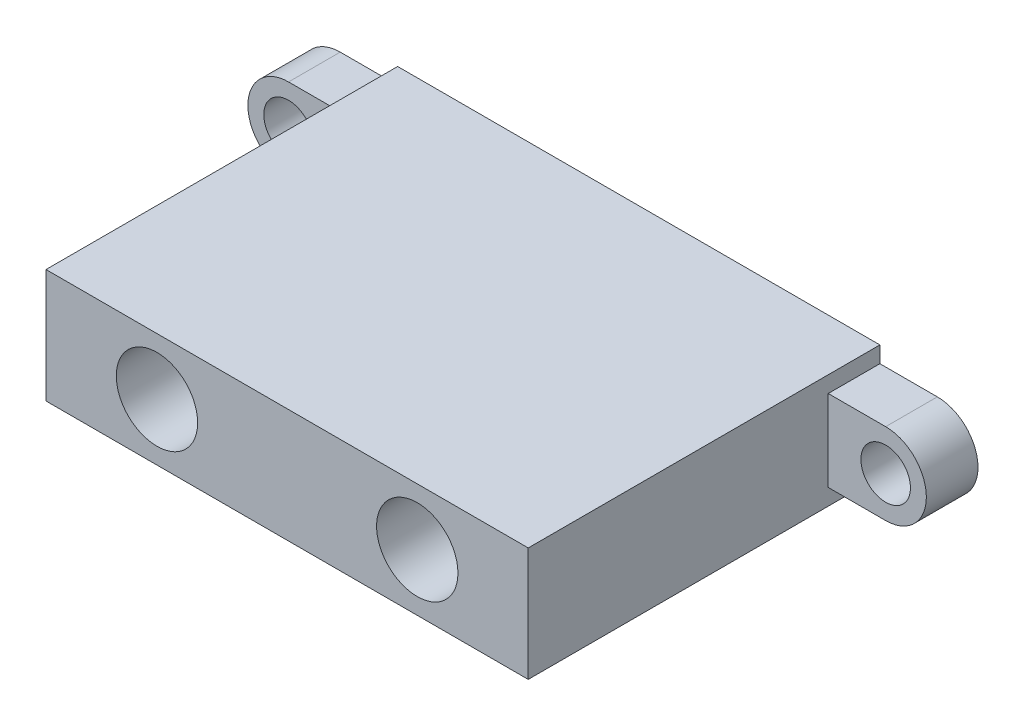
from build123d import *

# Parameters (mm, degrees)
SKETCH1_W           = 29.6418
SKETCH1_H           = 7
BOSS_EXTRUDE1_DEPTH = 21.6154
SKETCH2_R           = 1.524
BOSS_EXTRUDE2_DEPTH = 3.175
SKETCH3_R           = 2.5
CUT_EXTRUDE1_DEPTH  = 3.81


with BuildPart() as part:
    # Sketch1 → Boss-Extrude1 (new body)
    with BuildSketch(Plane.XY):
        with Locations((14.8209, 3.5)):
            Rectangle(SKETCH1_W, SKETCH1_H)
    extrude(amount=BOSS_EXTRUDE1_DEPTH)

    # Sketch2 → Boss-Extrude2 (add)
    with BuildSketch(Plane(origin=(0, 0, 0), x_dir=(-1, 0, 0), z_dir=(0, 0, -1))):
        with BuildLine():
            Line((-33.1724, 6), (3.5306, 6))
            ThreePointArc((3.5306, 6), (6.0306, 3.5), (3.5306, 1))
            Line((3.5306, 1), (-33.1724, 1))
            ThreePointArc((-33.1724, 1), (-35.6724, 3.5), (-33.1724, 6))
        make_face()
        with Locations((-33.1724, 3.5)):
            Circle(SKETCH2_R, mode=Mode.SUBTRACT)
        with Locations((3.5306, 3.5)):
            Circle(SKETCH2_R, mode=Mode.SUBTRACT)
    extrude(amount=-BOSS_EXTRUDE2_DEPTH)

    # Sketch3 → Cut-Extrude1 (cut)
    with BuildSketch(Plane.XY.offset(21.6154)):
        with Locations((6.8209, 3.5)):
            Circle(SKETCH3_R)
        with Locations((22.8209, 3.5)):
            Circle(SKETCH3_R)
    extrude(amount=-CUT_EXTRUDE1_DEPTH, mode=Mode.SUBTRACT)


solid = part.part
